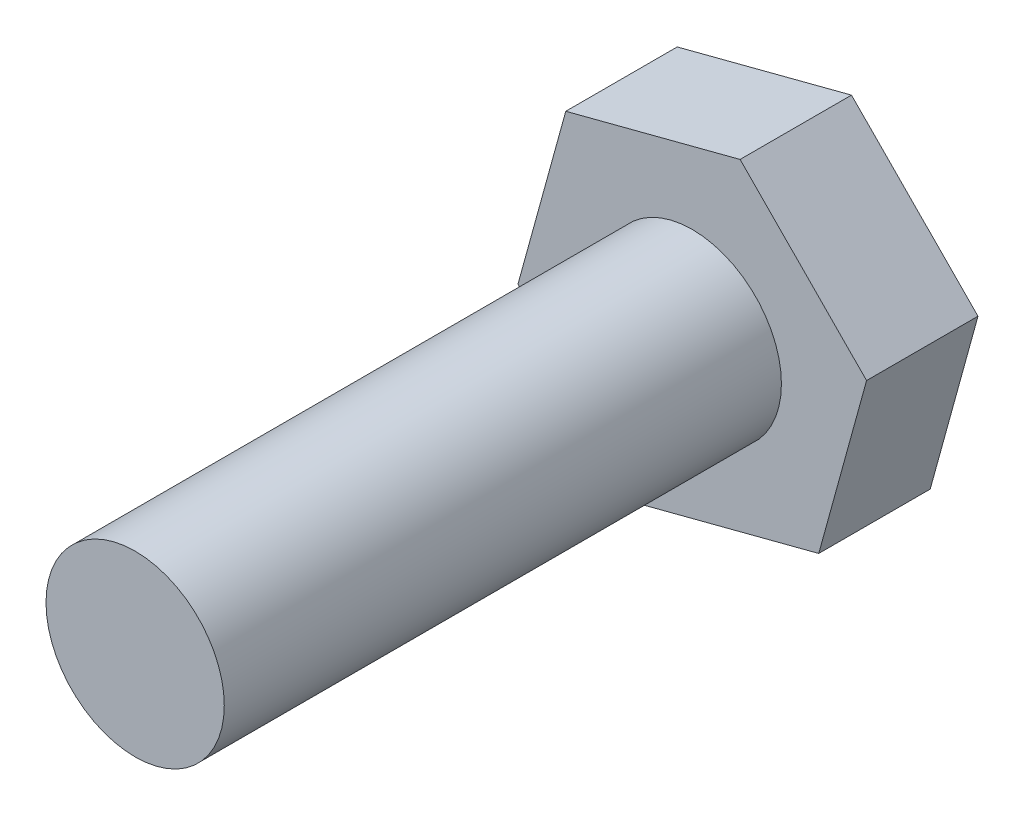
from build123d import *

# Parameters (mm, degrees)
BOSS_EXTRUDE1_DEPTH = 5
SKETCH2_R           = 4
BOSS_EXTRUDE2_DEPTH = 25


with BuildPart() as part:
    # Sketch1 → Boss-Extrude1 (new body)
    with BuildSketch(Plane.XY):
        Polygon((5.676195828, -5.754488184), (7.821630867, 2.038485692), (2.145435039, 7.792973876), (-5.676195828, 5.754488184), (-7.821630867, -2.038485692), (-2.145435039, -7.792973876), align=None)
    extrude(amount=BOSS_EXTRUDE1_DEPTH)

    # Sketch2 → Boss-Extrude2 (add)
    with BuildSketch(Plane.XY.offset(5)):
        Circle(SKETCH2_R)
    extrude(amount=BOSS_EXTRUDE2_DEPTH)


solid = part.part
